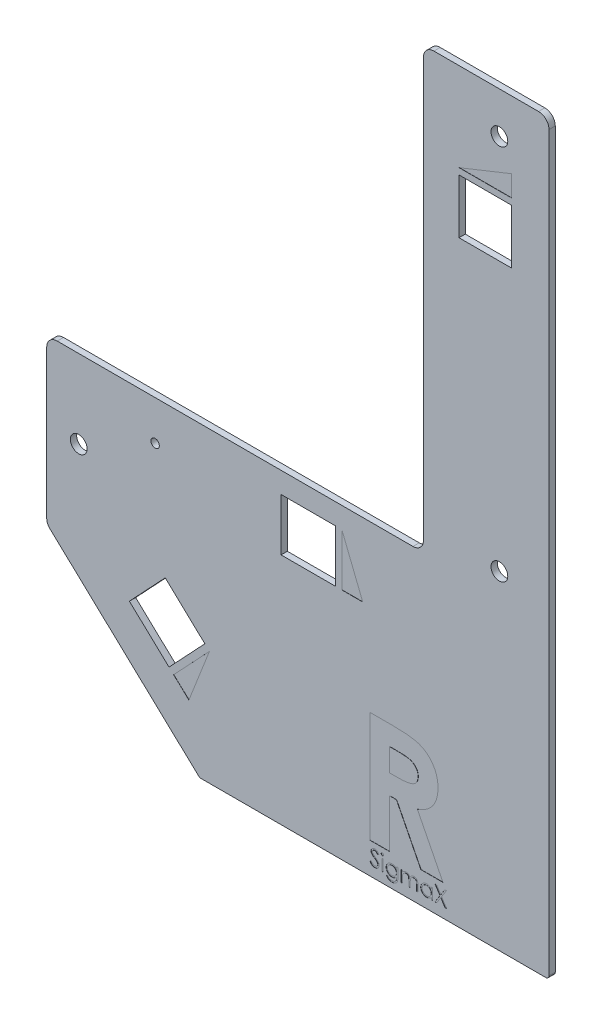
from build123d import *

# Parameters (mm, degrees)
SALIENTE_EXTRUIR1_DEPTH = 3
CROQUIS2_R              = 4
CROQUIS2_R_2            = 2
CROQUIS2_W              = 25
CROQUIS2_H              = 26
CROQUIS2_W_2            = 26
CROQUIS2_H_2            = 25
CORTAR_EXTRUIR1_DEPTH   = 3
CORTAR_EXTRUIR2_DEPTH   = 0.1
REDONDEO1_R             = 5
CROQUIS4_W              = 0.664850428
CROQUIS4_H              = 5.413782051
CORTAR_EXTRUIR3_DEPTH   = 0.1
CORTAR_EXTRUIR9_REACH   = 807.611
CROQUIS10_R             = 4


with BuildPart() as part:
    # Croquis1 → Saliente-Extruir1 (new body)
    with BuildSketch(Plane.XY):
        Polygon((676.577899016, -3.312104139), (676.577899016, -437.312104139), (591.996797016, -437.312104139), (436.577899016, -291.312104139), (436.577899016, -213.312104139), (616.577899016, -213.312104139), (616.577899016, -3.312104139), align=None)
    extrude(amount=SALIENTE_EXTRUIR1_DEPTH)

    # Croquis2 → Cortar-Extruir1 (cut)
    with BuildSketch(Plane.XY.offset(3)):
        with Locations((652.877899016, -23)):
            Circle(CROQUIS2_R)
        with Locations((652.877899016, -203)):
            Circle(CROQUIS2_R)
        with Locations((652.877899016, -383.180000139)):
            Circle(CROQUIS2_R)
        with Locations((488.377899016, -232.212104139)):
            Circle(CROQUIS2_R_2)
        with Locations((451.877899016, -250.812104139)):
            Circle(CROQUIS2_R)
        with Locations((646.077899016, -61.566115562)):
            Rectangle(CROQUIS2_W, CROQUIS2_H)
        with Locations((561.577899016, -235.812104139)):
            Rectangle(CROQUIS2_W_2, CROQUIS2_H_2)
        Polygon((476.073516686, -303.717618116), (495.023540448, -321.519207915), (512.140453717, -303.298031221), (493.190429955, -285.496441421), align=None)
    extrude(amount=-CORTAR_EXTRUIR1_DEPTH, mode=Mode.SUBTRACT)

    # Croquis3 → Cortar-Extruir2 (cut)
    # profile 1 of 4: a face of its own
    with BuildSketch(Plane.XY.offset(3)):
        Polygon((577.577899016, -248.312104139), (577.577899016, -223.312104139), (587.577899016, -248.312104139), align=None)
    # profile 2 of 4: a face of its own
    with BuildSketch(Plane.XY.offset(3)):
        Polygon((497.210081652, -323.573237508), (514.326994921, -305.352060813), (504.49855233, -330.420002815), align=None)
    # profile 3 of 4: a face of its own
    with BuildSketch(Plane.XY.offset(3)):
        Polygon((633.577899016, -45.566115562), (658.577899016, -35.566115562), (658.577899016, -45.566115562), align=None)
    # profile 4 of 4: a face of its own
    with BuildSketch(Plane.XY.offset(3)):
        with BuildLine():
            Line((590.974945428, -292.24933964), (602.041652159, -292.24933964))
            add(Edge.make_bspline(
                [(602.041652159, -292.24933964), (602.773158105, -292.251936067), (604.180050094, -292.256929726), (606.208711499, -292.335716439), (608.072315986, -292.445354618), (609.77362279, -292.612665388), (611.311904063, -292.834499245), (612.688701524, -293.096004654), (613.90397493, -293.394046133), (614.967973434, -293.76542933), (615.928179469, -294.184343946), (616.823224989, -294.665684521), (617.672856027, -295.204091176), (618.471393719, -295.813730847), (619.225777544, -296.483636267), (619.937430692, -297.214481761), (620.596296846, -298.012464599), (621.198296278, -298.87254254), (621.746970303, -299.777324812), (622.231883065, -300.728053685), (622.626214928, -301.72539033), (622.974649401, -302.754921074), (623.225615464, -303.831363263), (623.400158689, -304.944237549), (623.527952411, -306.097461368), (623.535299939, -306.880910429), (623.539047992, -307.280556254)],
                knots=[0, 0, 0, 0, 1.749336639, 3.364467119, 4.854658419, 6.213483162, 7.451590619, 8.570285859, 9.5643256, 10.440900261, 11.26203566, 12.067320669, 12.869050712, 13.665104639, 14.467235401, 15.27997916, 16.102287765, 16.939272006, 17.78853747, 18.631303466, 19.488103222, 20.351255419, 21.228522269, 22.127379805, 23.044756219, 24, 24, 24, 24], degree=3))
            add(Edge.make_bspline(
                [(623.539047992, -307.280556254), (623.529311897, -307.697694687), (623.51022119, -308.515627128), (623.407388254, -309.717103173), (623.219441949, -310.866591414), (622.934769929, -311.960726289), (622.607576417, -313.013125584), (622.172492976, -314.004371873), (621.68145831, -314.948881397), (621.098270785, -315.833293711), (620.458250966, -316.67725338), (619.71392138, -317.448425178), (618.913503151, -318.188256668), (618.012001854, -318.850407317), (617.049156505, -319.479649358), (616.00583638, -320.049910221), (614.888850543, -320.57552495), (614.103554183, -320.868644031), (613.701975343, -321.018537023)],
                knots=[0, 0, 0, 0, 1.099860209, 2.156625411, 3.176576793, 4.16617041, 5.135385252, 6.078461593, 7.016046972, 7.938469504, 8.868247731, 9.803980173, 10.76021508, 11.73834243, 12.748633912, 13.790971185, 14.870363756, 16, 16, 16, 16], degree=3))
            Line((613.701975343, -321.018537023), (625.913513804, -345.166006307))
            Line((625.913513804, -345.166006307), (615.355621176, -345.166006307))
            Line((615.355621176, -345.166006307), (603.695297992, -322.099766991))
            Line((603.695297992, -322.099766991), (600.472808676, -322.099766991))
            Line((600.472808676, -322.099766991), (600.472808676, -345.166006307))
            Line((600.472808676, -345.166006307), (590.974945428, -345.166006307))
            Line((590.974945428, -345.166006307), (590.974945428, -292.24933964))
        make_face()
        with BuildLine():
            Line((600.472808676, -312.601903743), (604.172311213, -312.601903743))
            add(Edge.make_bspline(
                [(604.172311213, -312.601903743), (604.624606151, -312.596809693), (605.49065377, -312.587055683), (606.736143993, -312.54181254), (607.86734615, -312.432798921), (608.889118004, -312.295064288), (609.806601017, -312.136029763), (610.611611566, -311.908123634), (611.316553634, -311.663916447), (611.913073631, -311.360430261), (612.422726609, -311.015300645), (612.862779336, -310.623224821), (613.226766038, -310.169446979), (613.526345658, -309.666298843), (613.759386033, -309.109330192), (613.929487653, -308.504655279), (614.024549304, -307.845386079), (614.035486471, -307.390400563), (614.041184744, -307.153352728)],
                knots=[0, 0, 0, 0, 1.688639943, 3.233382647, 4.650958383, 5.928841754, 7.082724185, 8.122798841, 9.049171256, 9.863274652, 10.613301712, 11.341792392, 12.054588806, 12.776240173, 13.521029143, 14.301969904, 15.115324896, 16, 16, 16, 16], degree=3))
            add(Edge.make_bspline(
                [(614.041184744, -307.153352728), (614.030411637, -306.872907833), (614.009249864, -306.322025807), (613.799259333, -305.528948853), (613.464999768, -304.794901871), (613.006821456, -304.123201467), (612.429805438, -303.534342523), (611.767634033, -303.015258675), (611.006015983, -302.604806009), (610.300814981, -302.3340758), (609.659246905, -302.172095123), (609.080251956, -302.051388555), (608.409772321, -301.965840346), (607.647301821, -301.875101242), (606.794784022, -301.816261527), (605.847572191, -301.773320262), (604.808386714, -301.755750882), (604.083975738, -301.75013426), (603.705898286, -301.747202888)],
                knots=[0, 0, 0, 0, 1.020303359, 2.004196876, 2.966617323, 3.9489082, 4.950758222, 5.960522915, 7.003732012, 8.091992268, 8.70421221, 9.413913587, 10.24622431, 11.166358409, 12.212345909, 13.359657661, 14.621978493, 16, 16, 16, 16], degree=3))
            Line((603.705898286, -301.747202888), (600.472808676, -301.747202888))
            Line((600.472808676, -301.747202888), (600.472808676, -312.601903743))
        make_face(mode=Mode.SUBTRACT)
    extrude(amount=-CORTAR_EXTRUIR2_DEPTH, mode=Mode.SUBTRACT)

    # Redondeo1
    redondeo1_edges = [part.edges().sort_by_distance(p)[0] for p in [
        (591.996797016, -437.312104139, 1.5),
        (676.577899016, -437.312104139, 1.5),
        (676.577899016, -3.312104139, 1.5),
        (616.577899016, -3.312104139, 1.5),
        (616.577899016, -213.312104139, 1.5),
        (436.577899016, -213.312104139, 1.5),
        (436.577899016, -291.312104139, 1.5),
    ]]
    fillet(redondeo1_edges, radius=REDONDEO1_R)

    # Croquis4 → Cortar-Extruir3 (cut)
    # profile 1 of 7: a face of its own
    with BuildSketch(Plane.XY.offset(3)):
        with BuildLine():
            Line((591.064902693, -353.736874696), (591.691168051, -353.36141229))
            add(Edge.make_bspline(
                [(591.691168051, -353.36141229), (591.749414986, -353.458915238), (591.861013867, -353.645727124), (592.047177577, -353.898156643), (592.240075573, -354.112706541), (592.441136329, -354.288128694), (592.649132585, -354.426238838), (592.865422166, -354.524033561), (593.089276199, -354.585027376), (593.241620787, -354.592435892), (593.317677132, -354.596134512)],
                knots=[0, 0, 0, 0, 1.272034388, 2.437168799, 3.508375237, 4.49857839, 5.41946034, 6.295179144, 7.148887113, 8, 8, 8, 8], degree=3))
            add(Edge.make_bspline(
                [(593.317677132, -354.596134512), (593.382630987, -354.594325455), (593.511402156, -354.590738996), (593.700975571, -354.556277965), (593.885087052, -354.503335625), (594.059942002, -354.427514654), (594.223127719, -354.335781526), (594.366228558, -354.224982117), (594.489939497, -354.100932314), (594.591135457, -353.962539029), (594.668774865, -353.813701064), (594.728448076, -353.660928634), (594.761563482, -353.501821831), (594.766551944, -353.394696351), (594.76906936, -353.340635714)],
                knots=[0, 0, 0, 0, 1.095163259, 2.171163733, 3.241058638, 4.321873601, 5.38011039, 6.391990106, 7.366004449, 8.327778327, 9.272591725, 10.192022065, 11.087607919, 12, 12, 12, 12], degree=3))
            add(Edge.make_bspline(
                [(594.76906936, -353.340635714), (594.765948735, -353.278954249), (594.759604962, -353.153564843), (594.705986663, -352.968568911), (594.62163909, -352.785492972), (594.543824828, -352.672248626), (594.503425997, -352.613455559)],
                knots=[0, 0, 0, 0, 0.938893495, 1.908633276, 2.914225137, 4, 4, 4, 4], degree=3))
            add(Edge.make_bspline(
                [(594.503425997, -352.613455559), (594.47025653, -352.571023116), (594.400621384, -352.481941509), (594.280907982, -352.349342427), (594.14043304, -352.212566774), (593.984003849, -352.06639177), (593.805922144, -351.917615933), (593.611765572, -351.759144745), (593.396577071, -351.59700474), (593.245659803, -351.488266143), (593.167788978, -351.432158818)],
                knots=[0, 0, 0, 0, 0.722233717, 1.516239348, 2.393582979, 3.351407094, 4.387010283, 5.505090956, 6.712668013, 8, 8, 8, 8], degree=3))
            add(Edge.make_bspline(
                [(593.167788978, -351.432158818), (593.089844852, -351.376641641), (592.94082162, -351.270497025), (592.732417621, -351.112965624), (592.546056841, -350.968939434), (592.382567589, -350.837062608), (592.242021776, -350.717317261), (592.123311889, -350.61085329), (592.029461944, -350.51479142), (591.977274298, -350.452473913), (591.953843331, -350.424494889)],
                knots=[0, 0, 0, 0, 1.452282411, 2.77665338, 3.964542531, 5.026858415, 5.96415736, 6.766646006, 7.446254459, 8, 8, 8, 8], degree=3))
            add(Edge.make_bspline(
                [(591.953843331, -350.424494889), (591.921093111, -350.380889361), (591.856685406, -350.295133238), (591.771667361, -350.161095622), (591.699406133, -350.023886377), (591.642759197, -349.883136797), (591.595057534, -349.740822864), (591.562973247, -349.595087728), (591.542883124, -349.446585318), (591.540825752, -349.346650075), (591.539795855, -349.296623628)],
                knots=[0, 0, 0, 0, 1.068054152, 2.10047183, 3.106115577, 4.101338837, 5.06977816, 6.043150881, 7.020423561, 8, 8, 8, 8], degree=3))
            add(Edge.make_bspline(
                [(591.539795855, -349.296623628), (591.542558548, -349.218243939), (591.548024882, -349.06315987), (591.594253977, -348.836611279), (591.667221602, -348.620316696), (591.769445781, -348.41641749), (591.901223845, -348.23022283), (592.053721157, -348.059590949), (592.23535547, -347.91614745), (592.434645189, -347.79081526), (592.652781176, -347.692716385), (592.881361922, -347.618715644), (593.120750724, -347.576786048), (593.282894026, -347.570768863), (593.365166448, -347.567715709)],
                knots=[0, 0, 0, 0, 1.005424448, 1.989358655, 2.955360095, 3.929531133, 4.905563448, 5.876582895, 6.856512386, 7.866279853, 8.892233794, 9.918561126, 10.94386622, 12, 12, 12, 12], degree=3))
            add(Edge.make_bspline(
                [(593.365166448, -347.567715709), (593.452466461, -347.570726776), (593.626078322, -347.576714829), (593.881452495, -347.628779603), (594.127326011, -347.714929359), (594.325114255, -347.812695351), (594.479911933, -347.910340181), (594.597964218, -347.999282143), (594.717592822, -348.101676122), (594.839762705, -348.21779486), (594.962403767, -348.348703816), (595.087336741, -348.493506441), (595.214853777, -348.651317818), (595.296887014, -348.763976344), (595.338941154, -348.821730466)],
                knots=[0, 0, 0, 0, 1.286793592, 2.559021753, 3.825965368, 5.121522368, 5.803751409, 6.523245864, 7.299691795, 8.125521123, 9.008227632, 9.944561021, 10.946284179, 12, 12, 12, 12], degree=3))
            Line((595.338941154, -348.821730466), (594.737904496, -349.277331093))
            add(Edge.make_bspline(
                [(594.737904496, -349.277331093), (594.701612272, -349.230576699), (594.631721935, -349.140538666), (594.525614521, -349.014446048), (594.425604883, -348.8992645), (594.327073203, -348.799219979), (594.23522335, -348.708833796), (594.14607561, -348.631448978), (594.0609129, -348.566307301), (593.953562106, -348.496788432), (593.818692936, -348.427877166), (593.649392334, -348.369564951), (593.472468052, -348.334523403), (593.351966998, -348.329890258), (593.290964392, -348.327544769)],
                knots=[0, 0, 0, 0, 1.181633172, 2.275549214, 3.290209073, 4.226197932, 5.078386478, 5.862611352, 6.581680152, 7.217281963, 8.414376989, 9.595101626, 10.782541182, 12, 12, 12, 12], degree=3))
            add(Edge.make_bspline(
                [(593.290964392, -348.327544769), (593.214433086, -348.330109533), (593.066849672, -348.335055441), (592.857320339, -348.389072743), (592.668738198, -348.474124347), (592.506701935, -348.593324384), (592.371792, -348.734550486), (592.274202113, -348.897065729), (592.215464264, -349.076521814), (592.208296639, -349.201704987), (592.204646283, -349.265458764)],
                knots=[0, 0, 0, 0, 1.14458467, 2.207223713, 3.21896685, 4.227309161, 5.202851033, 6.127160689, 7.046193047, 8, 8, 8, 8], degree=3))
            add(Edge.make_bspline(
                [(592.204646283, -349.265458764), (592.205478401, -349.305149394), (592.207143998, -349.384595555), (592.230373986, -349.501967731), (592.260217566, -349.6190434), (592.307509469, -349.7352962), (592.372798695, -349.85275926), (592.458534651, -349.973455271), (592.566512828, -350.098448055), (592.649225838, -350.179743663), (592.692895815, -350.222665295)],
                knots=[0, 0, 0, 0, 0.858281714, 1.717966888, 2.583508476, 3.4729293, 4.427298488, 5.488583878, 6.674047936, 8, 8, 8, 8], degree=3))
            add(Edge.make_bspline(
                [(592.692895815, -350.222665295), (592.709112387, -350.237136999), (592.747639249, -350.271518457), (592.818073292, -350.327805451), (592.911085548, -350.397237986), (593.024247207, -350.483147806), (593.15964479, -350.582803567), (593.317293183, -350.694931046), (593.495435095, -350.823170268), (593.621846483, -350.912827062), (593.688687415, -350.960233738)],
                knots=[0, 0, 0, 0, 0.420754252, 0.999615792, 1.744751191, 2.668019286, 3.750313428, 4.999500688, 6.413464383, 8, 8, 8, 8], degree=3))
            add(Edge.make_bspline(
                [(593.688687415, -350.960233738), (593.769090932, -351.018741282), (593.924781198, -351.132033033), (594.146306408, -351.302246222), (594.347164969, -351.468717332), (594.528062083, -351.630383267), (594.690784873, -351.786017731), (594.833528048, -351.937493129), (594.957746072, -352.083724258), (595.091475417, -352.271202876), (595.228122802, -352.501456172), (595.345473993, -352.783561776), (595.419469161, -353.066763988), (595.429145536, -353.257109125), (595.433919787, -353.351024002)],
                knots=[0, 0, 0, 0, 1.163667725, 2.253281268, 3.268753668, 4.215851969, 5.092017293, 5.902905408, 6.650798638, 7.335211899, 8.59617414, 9.77448103, 10.901945474, 12, 12, 12, 12], degree=3))
            add(Edge.make_bspline(
                [(595.433919787, -353.351024002), (595.432528845, -353.417441541), (595.429773971, -353.548986837), (595.398106704, -353.742143416), (595.351710079, -353.929745424), (595.281781267, -354.109473945), (595.196430582, -354.284617026), (595.088128691, -354.450580415), (594.962594091, -354.611037292), (594.818589289, -354.761709015), (594.661012129, -354.90002513), (594.494464975, -355.023064977), (594.318675231, -355.125656262), (594.134596527, -355.209372211), (593.942186581, -355.274848156), (593.741510106, -355.322288729), (593.532236307, -355.351404984), (593.389995288, -355.354427079), (593.317677132, -355.355963572)],
                knots=[0, 0, 0, 0, 0.983748083, 1.948392443, 2.894712957, 3.844097841, 4.80183111, 5.778335162, 6.776009319, 7.81870978, 8.863265674, 9.881300176, 10.883814829, 11.87499822, 12.874611388, 13.892143829, 14.928324115, 16, 16, 16, 16], degree=3))
            add(Edge.make_bspline(
                [(593.317677132, -355.355963572), (593.261722323, -355.354881571), (593.150517397, -355.352731196), (592.986032327, -355.333720819), (592.824870197, -355.306824116), (592.6690533, -355.264122335), (592.516574112, -355.212312733), (592.368095799, -355.148519929), (592.223546402, -355.072071853), (592.082115851, -354.984664051), (591.944163848, -354.882941825), (591.810984308, -354.764464591), (591.678207532, -354.632499938), (591.549752543, -354.483464246), (591.423021054, -354.319765304), (591.300511754, -354.139871532), (591.179688785, -353.9447628), (591.103879378, -353.807465035), (591.064902693, -353.736874696)],
                knots=[0, 0, 0, 0, 0.915332311, 1.819136955, 2.706846663, 3.586547465, 4.459518054, 5.340707479, 6.227863349, 7.133153174, 8.059268498, 9.028702269, 10.047606654, 11.120612155, 12.245963614, 13.433783089, 14.680604001, 16, 16, 16, 16], degree=3))
        make_face()
    # profile 2 of 7: a face of its own
    with BuildSketch(Plane.XY.offset(3)):
        with BuildLine():
            add(Edge.make_bspline(
                [(596.998099141, -347.472737076), (597.039355759, -347.474650865), (597.120144142, -347.478398432), (597.236969892, -347.510490226), (597.343347234, -347.564887893), (597.437703435, -347.637869884), (597.518669929, -347.72369954), (597.575355766, -347.823735256), (597.611788671, -347.931809375), (597.616188279, -348.007194647), (597.618428334, -348.045576953)],
                knots=[0, 0, 0, 0, 1.055194115, 2.066272739, 3.074728998, 4.095836921, 5.109056067, 6.073838105, 7.019297344, 8, 8, 8, 8], degree=3))
            add(Edge.make_bspline(
                [(597.618428334, -348.045576953), (597.616137762, -348.082962903), (597.611609573, -348.1568705), (597.575383907, -348.263071016), (597.518186836, -348.361716749), (597.437755354, -348.447379752), (597.343333476, -348.520321398), (597.236973546, -348.574729762), (597.12014318, -348.606818719), (597.039355434, -348.610566677), (596.998099141, -348.612480666)],
                knots=[0, 0, 0, 0, 0.96129708, 1.900370562, 2.859976407, 3.87933698, 4.906634145, 5.921202961, 6.938410037, 8, 8, 8, 8], degree=3))
            add(Edge.make_bspline(
                [(596.998099141, -348.612480666), (596.957314625, -348.610639758), (596.877932893, -348.607056672), (596.762856411, -348.574100134), (596.657386108, -348.520302779), (596.562845884, -348.447857354), (596.484041975, -348.361190655), (596.426683853, -348.263131216), (596.390541851, -348.156855173), (596.386002387, -348.082957754), (596.383706112, -348.045576953)],
                knots=[0, 0, 0, 0, 1.054934014, 2.053291228, 3.073705704, 4.106921865, 5.123545215, 6.088680038, 7.033164197, 8, 8, 8, 8], degree=3))
            add(Edge.make_bspline(
                [(596.383706112, -348.045576953), (596.385952078, -348.007199988), (596.390363299, -347.931825208), (596.426710945, -347.823674055), (596.483564204, -347.724229876), (596.562898064, -347.637392569), (596.657372221, -347.564906398), (596.762859999, -347.511119821), (596.877931946, -347.478160486), (596.957314303, -347.474577786), (596.998099141, -347.472737076)],
                knots=[0, 0, 0, 0, 0.98631895, 1.937192651, 2.907499808, 3.917963147, 4.944918757, 5.95915025, 6.951458133, 8, 8, 8, 8], degree=3))
        make_face()
    # profile 3 of 7: a face of its own
    with BuildSketch(Plane.XY.offset(3)):
        with Locations((597.001067223, -352.459115282)):
            Rectangle(CROQUIS4_W, CROQUIS4_H)
    # profile 4 of 7: a face of its own
    with BuildSketch(Plane.XY.offset(3)):
        with BuildLine():
            Line((603.697060813, -349.752224256), (604.36191124, -349.752224256))
            Line((604.36191124, -349.752224256), (604.36191124, -354.048523334))
            add(Edge.make_bspline(
                [(604.36191124, -354.048523334), (604.361324833, -354.14004291), (604.360192927, -354.316697735), (604.352041704, -354.572133427), (604.334852938, -354.808069975), (604.315361229, -355.025583422), (604.287322346, -355.223665555), (604.253082369, -355.402907438), (604.214483514, -355.563481079), (604.180574054, -355.662381992), (604.164533769, -355.709165361)],
                knots=[0, 0, 0, 0, 1.307562039, 2.523909702, 3.650326591, 4.686913197, 5.643429486, 6.506965704, 7.293745905, 8, 8, 8, 8], degree=3))
            add(Edge.make_bspline(
                [(604.164533769, -355.709165361), (604.140849881, -355.769977029), (604.094190236, -355.889782134), (604.006802312, -356.059611446), (603.90894055, -356.219517971), (603.797166261, -356.368610577), (603.671984892, -356.506140808), (603.536345734, -356.635096606), (603.387607162, -356.752749761), (603.225854221, -356.857070307), (603.054815631, -356.951022905), (602.874589715, -357.032401472), (602.686192754, -357.103281958), (602.487854966, -357.156373875), (602.28268597, -357.202379034), (602.068273074, -357.232318619), (601.845868988, -357.252695892), (601.694642933, -357.254580218), (601.617919186, -357.255536222)],
                knots=[0, 0, 0, 0, 0.981931301, 1.934503488, 2.87077864, 3.801706999, 4.735015492, 5.667491629, 6.616593066, 7.585388521, 8.561939025, 9.551802639, 10.560317337, 11.588439944, 12.640189604, 13.723962949, 14.845264515, 16, 16, 16, 16], degree=3))
            add(Edge.make_bspline(
                [(601.617919186, -357.255536222), (601.505979831, -357.253723327), (601.287332196, -357.250182256), (600.968551628, -357.208926485), (600.665794805, -357.150603062), (600.383062204, -357.062326574), (600.122140499, -356.954298279), (599.88481163, -356.830272295), (599.673206119, -356.688054925), (599.482444344, -356.526128653), (599.310271312, -356.33358886), (599.148288548, -356.10668464), (598.992372888, -355.841959725), (598.900999271, -355.647665148), (598.853150556, -355.545920837)],
                knots=[0, 0, 0, 0, 1.157897085, 2.2616841, 3.32207898, 4.345638746, 5.321241055, 6.241986252, 7.112515963, 7.955008012, 8.825025602, 9.77857164, 10.836726669, 12, 12, 12, 12], degree=3))
            Line((598.853150556, -355.545920837), (599.518000984, -355.545920837))
            add(Edge.make_bspline(
                [(599.518000984, -355.545920837), (599.57147266, -355.630811607), (599.676003203, -355.79676261), (599.871474154, -356.011632123), (600.085694212, -356.195260079), (600.325892874, -356.343237884), (600.59306958, -356.454806942), (600.887385066, -356.53434132), (601.211234265, -356.581958418), (601.436697819, -356.587697324), (601.554105417, -356.590685794)],
                knots=[0, 0, 0, 0, 0.997731894, 1.950442991, 2.880492273, 3.800895997, 4.748200782, 5.754801363, 6.83083817, 8, 8, 8, 8], degree=3))
            add(Edge.make_bspline(
                [(601.554105417, -356.590685794), (601.670028669, -356.587658646), (601.893517093, -356.581822607), (602.214893068, -356.534320069), (602.508252354, -356.454789634), (602.771904778, -356.343435216), (603.002739488, -356.207015189), (603.201731536, -356.054615032), (603.362904434, -355.882781908), (603.471305214, -355.724493752), (603.538688488, -355.583472678), (603.581598056, -355.46207635), (603.616467958, -355.324804425), (603.64563528, -355.172117117), (603.669703714, -355.003796276), (603.684949815, -354.819457039), (603.695968782, -354.619518352), (603.696688385, -354.480891209), (603.697060813, -354.409145329)],
                knots=[0, 0, 0, 0, 1.570740765, 3.028230971, 4.391408896, 5.680370741, 6.894727393, 8.017376726, 9.065722033, 10.075533815, 10.603371122, 11.180248986, 11.817768598, 12.521299649, 13.286540596, 14.121245857, 15.027658897, 16, 16, 16, 16], degree=3))
            Line((603.697060813, -354.409145329), (603.697060813, -354.128661555))
            add(Edge.make_bspline(
                [(603.697060813, -354.128661555), (603.629579114, -354.208971703), (603.495802699, -354.368179368), (603.26477419, -354.576801499), (603.012431719, -354.756477142), (602.739204888, -354.903836585), (602.451786442, -355.0216956), (602.153289387, -355.104124867), (601.846389537, -355.157379989), (601.638422487, -355.163110475), (601.533328841, -355.166006307)],
                knots=[0, 0, 0, 0, 1.012485704, 2.007162095, 2.997754123, 3.998611389, 4.999708251, 5.992315798, 6.98544096, 8, 8, 8, 8], degree=3))
            add(Edge.make_bspline(
                [(601.533328841, -355.166006307), (601.471445405, -355.164916168), (601.348410858, -355.16274879), (601.165626643, -355.143786044), (600.985539715, -355.11627204), (600.808570076, -355.075882994), (600.634462361, -355.024042173), (600.463504291, -354.959236742), (600.29431166, -354.885968075), (600.129959906, -354.799665641), (599.97208593, -354.703648758), (599.821880521, -354.599638106), (599.680130447, -354.488178063), (599.548184877, -354.36816954), (599.426216889, -354.239786229), (599.312586035, -354.104396709), (599.209171317, -353.96011044), (599.113850643, -353.809558379), (599.031178828, -353.651737757), (598.958610241, -353.490070789), (598.895513667, -353.324903152), (598.845210234, -353.155681869), (598.806790377, -352.982513625), (598.77819373, -352.805682108), (598.761973858, -352.624642788), (598.759444602, -352.502677599), (598.758171924, -352.441306788)],
                knots=[0, 0, 0, 0, 1.028754217, 2.045334182, 3.052854819, 4.056607503, 5.061168794, 6.071104265, 7.095078842, 8.125279047, 9.155117945, 10.165957491, 11.161587969, 12.151493252, 13.128948131, 14.104219989, 15.088194871, 16.07871515, 17.064853787, 18.047899887, 19.02414258, 20.002704429, 20.980574569, 21.971845993, 22.979467364, 24, 24, 24, 24], degree=3))
            add(Edge.make_bspline(
                [(598.758171924, -352.441306788), (598.759270826, -352.379916901), (598.761464373, -352.2573749), (598.780410613, -352.075596868), (598.807436614, -351.896252896), (598.850209725, -351.721191563), (598.901692398, -351.548419172), (598.96545396, -351.379211873), (599.042117, -351.213518128), (599.12892097, -351.051215237), (599.226465633, -350.894481118), (599.333426051, -350.745623051), (599.449931351, -350.605736421), (599.574374239, -350.473409994), (599.708274185, -350.3499205), (599.851561919, -350.235567658), (600.002825016, -350.128434636), (600.162532278, -350.030832306), (600.328219417, -349.944509884), (600.495676998, -349.86574322), (600.667123262, -349.803229334), (600.839361804, -349.748147108), (601.015425957, -349.709125944), (601.19315694, -349.679022199), (601.373163222, -349.660681873), (601.493713516, -349.658392518), (601.554105417, -349.657245623)],
                knots=[0, 0, 0, 0, 1.008818848, 2.013730394, 3.001654427, 3.987803273, 4.973046549, 5.963777569, 6.957074694, 7.972068341, 8.987420212, 9.989399531, 10.982630087, 11.977756091, 12.973280677, 13.973972381, 14.989194003, 16.018387222, 17.047741039, 18.059210846, 19.057554164, 20.045176975, 21.029480261, 22.018708529, 23.007435371, 24, 24, 24, 24], degree=3))
            add(Edge.make_bspline(
                [(601.554105417, -349.657245623), (601.653696571, -349.660117248), (601.8503585, -349.665787826), (602.139772455, -349.710282583), (602.419050196, -349.781220578), (602.689767663, -349.882853663), (602.954130124, -350.021601244), (603.211266295, -350.204360484), (603.461920129, -350.432770703), (603.616601537, -350.607930933), (603.697060813, -350.699042498)],
                knots=[0, 0, 0, 0, 0.96728863, 1.910097829, 2.838038873, 3.762875196, 4.71315279, 5.730631239, 6.819562287, 8, 8, 8, 8], degree=3))
            Line((603.697060813, -350.699042498), (603.697060813, -349.752224256))
        make_face()
        with BuildLine():
            add(Edge.make_bspline(
                [(601.607530898, -350.322096051), (601.510310908, -350.325400306), (601.317835943, -350.331942031), (601.035708951, -350.387789674), (600.763342776, -350.475305162), (600.505944619, -350.600490365), (600.264841237, -350.753089835), (600.050899533, -350.93796011), (599.863775794, -351.14908956), (599.705485242, -351.38456925), (599.579477183, -351.6386164), (599.490273611, -351.906397454), (599.432594395, -352.183585522), (599.426228199, -352.372757532), (599.423022351, -352.468019528)],
                knots=[0, 0, 0, 0, 1.026226791, 2.031711442, 3.026614839, 4.04107745, 5.047145931, 6.032893242, 7.017642609, 8.019221815, 9.021877557, 10.003543541, 10.994637589, 12, 12, 12, 12], degree=3))
            add(Edge.make_bspline(
                [(599.423022351, -352.468019528), (599.424558536, -352.539844955), (599.427579764, -352.681104566), (599.456628003, -352.888406443), (599.503577713, -353.085849774), (599.570119799, -353.273446499), (599.65256967, -353.452272649), (599.756270189, -353.621096362), (599.878298079, -353.78006799), (600.017698227, -353.928011733), (600.171318236, -354.062760783), (600.337940541, -354.181162969), (600.517339153, -354.278001995), (600.705101901, -354.361696768), (600.905784668, -354.422824128), (601.1164969, -354.469472877), (601.338729324, -354.496161414), (601.490222839, -354.499469336), (601.567461788, -354.50115588)],
                knots=[0, 0, 0, 0, 1.039728707, 2.044842319, 3.024901384, 3.974314358, 4.923051295, 5.871625912, 6.837440708, 7.820715446, 8.810779094, 9.792721783, 10.773906224, 11.758876063, 12.764959493, 13.806266761, 14.881525401, 16, 16, 16, 16], degree=3))
            add(Edge.make_bspline(
                [(601.567461788, -354.50115588), (601.645701742, -354.499531107), (601.798699145, -354.496353882), (602.022157627, -354.469041477), (602.233893594, -354.424968293), (602.433712901, -354.362393223), (602.622370007, -354.282548851), (602.797745608, -354.181506344), (602.963600089, -354.066434963), (603.114637823, -353.932212866), (603.251213973, -353.784289627), (603.370235763, -353.623327932), (603.47165468, -353.451749834), (603.555639082, -353.269574672), (603.619755464, -353.075386691), (603.662763813, -352.869671338), (603.692834757, -352.653414174), (603.695630714, -352.50522927), (603.697060813, -352.429434459)],
                knots=[0, 0, 0, 0, 1.121943988, 2.193949579, 3.223793937, 4.220241907, 5.192961521, 6.155822191, 7.11847367, 8.083710714, 9.04790392, 10.001595906, 10.949595423, 11.902125208, 12.873731292, 13.87582262, 14.913508608, 16, 16, 16, 16], degree=3))
            add(Edge.make_bspline(
                [(603.697060813, -352.429434459), (603.694225393, -352.330760001), (603.68868598, -352.137984786), (603.63641033, -351.857088793), (603.552124218, -351.592995101), (603.433915259, -351.346538952), (603.285786674, -351.120331738), (603.107371044, -350.918562934), (602.90174528, -350.740972788), (602.669500168, -350.593021611), (602.419633075, -350.473503108), (602.158179877, -350.383837357), (601.885528733, -350.333049391), (601.700730166, -350.325768177), (601.607530898, -350.322096051)],
                knots=[0, 0, 0, 0, 1.070913519, 2.092188694, 3.091357305, 4.074328408, 5.051968682, 6.018948707, 6.99050112, 7.9935919, 9.000589572, 9.992915277, 10.987769056, 12, 12, 12, 12], degree=3))
        make_face(mode=Mode.SUBTRACT)
    # profile 5 of 7: a face of its own
    with BuildSketch(Plane.XY.offset(3)):
        with BuildLine():
            Line((605.88156936, -349.752224256), (606.546419787, -349.752224256))
            Line((606.546419787, -349.752224256), (606.546419787, -350.693106334))
            add(Edge.make_bspline(
                [(606.546419787, -350.693106334), (606.606287481, -350.610794243), (606.720999722, -350.453076387), (606.909098687, -350.245240285), (607.097008125, -350.068862358), (607.232333783, -349.97627328), (607.2973446, -349.931793233)],
                knots=[0, 0, 0, 0, 1.134379233, 2.173579362, 3.122582517, 4, 4, 4, 4], degree=3))
            add(Edge.make_bspline(
                [(607.2973446, -349.931793233), (607.385958135, -349.889448543), (607.561637023, -349.805498975), (607.839807715, -349.720337942), (608.124445766, -349.668003144), (608.316656485, -349.660845903), (608.413343532, -349.657245623)],
                knots=[0, 0, 0, 0, 1.014936303, 2.012140481, 3.000054389, 4, 4, 4, 4], degree=3))
            add(Edge.make_bspline(
                [(608.413343532, -349.657245623), (608.478733708, -349.659458155), (608.60813735, -349.663836638), (608.799873674, -349.692327045), (608.985841069, -349.741573778), (609.164940765, -349.810169281), (609.333682869, -349.893241435), (609.488388338, -349.990713316), (609.627292912, -350.100138793), (609.750326387, -350.226459201), (609.860962491, -350.373221668), (609.962729383, -350.544384328), (610.056762749, -350.743790544), (610.108877852, -350.888499722), (610.136315286, -350.964685861)],
                knots=[0, 0, 0, 0, 1.009824226, 1.998387844, 2.986035974, 3.974953746, 4.955485308, 5.885931332, 6.793869504, 7.679848016, 8.601185859, 9.625726857, 10.749998409, 12, 12, 12, 12], degree=3))
            add(Edge.make_bspline(
                [(610.136315286, -350.964685861), (610.165337435, -350.912352507), (610.222448948, -350.809367815), (610.31834588, -350.663617827), (610.418819382, -350.527290118), (610.524725726, -350.400276519), (610.635691102, -350.283204257), (610.752237732, -350.175686265), (610.873702186, -350.077260812), (611.042595761, -349.962276791), (611.262332446, -349.840142624), (611.539378956, -349.734249084), (611.827563486, -349.668809946), (612.023180947, -349.661125869), (612.121962322, -349.657245623)],
                knots=[0, 0, 0, 0, 0.86119277, 1.694706429, 2.50939023, 3.298075842, 4.073795165, 4.829715201, 5.57930267, 6.321991688, 7.768977793, 9.186738141, 10.579381044, 12, 12, 12, 12], degree=3))
            add(Edge.make_bspline(
                [(612.121962322, -349.657245623), (612.212728085, -349.660668741), (612.390365496, -349.667368114), (612.648974041, -349.719974633), (612.890150863, -349.810308986), (613.113410674, -349.933570183), (613.314832279, -350.088466121), (613.489915133, -350.272761827), (613.637595736, -350.485153713), (613.734070523, -350.684950089), (613.799507832, -350.86134321), (613.839854112, -351.01163986), (613.875498133, -351.177060647), (613.905091769, -351.357803367), (613.926721037, -351.554506488), (613.942745718, -351.766848109), (613.953591674, -351.994993262), (613.95435806, -352.152400237), (613.95475312, -352.233541029)],
                knots=[0, 0, 0, 0, 1.209669288, 2.367440248, 3.500751976, 4.631527125, 5.755587489, 6.87532382, 8.007944318, 9.190864318, 9.82315674, 10.514484317, 11.263564316, 12.079023757, 12.955305781, 13.901327259, 14.918167583, 16, 16, 16, 16], degree=3))
            Line((613.95475312, -352.233541029), (613.95475312, -355.166006307))
            Line((613.95475312, -355.166006307), (613.289902693, -355.166006307))
            Line((613.289902693, -355.166006307), (613.289902693, -352.230572947))
            add(Edge.make_bspline(
                [(613.289902693, -352.230572947), (613.289737841, -352.161314399), (613.28942102, -352.028210002), (613.283719499, -351.837175647), (613.272976751, -351.663040958), (613.260415099, -351.506043371), (613.242965703, -351.365816769), (613.220431814, -351.242642816), (613.196560725, -351.135552582), (613.156902877, -351.016837115), (613.093513173, -350.885878503), (612.996956174, -350.744646934), (612.875311115, -350.62170924), (612.734848784, -350.514990469), (612.574937909, -350.428220596), (612.398694245, -350.366253042), (612.207212003, -350.327892949), (612.074660434, -350.324070216), (612.006207113, -350.322096051)],
                knots=[0, 0, 0, 0, 1.253487763, 2.409012846, 3.458416907, 4.410876679, 5.259312806, 6.014470957, 6.676830364, 7.243083969, 8.276244668, 9.299465089, 10.325150304, 11.392391894, 12.482080715, 13.603491619, 14.762376348, 16, 16, 16, 16], degree=3))
            add(Edge.make_bspline(
                [(612.006207113, -350.322096051), (611.922239043, -350.325093584), (611.756286215, -350.331017849), (611.514043269, -350.391499213), (611.281271284, -350.482685744), (611.064915919, -350.614834445), (610.865890429, -350.773178815), (610.694652989, -350.961455459), (610.55319153, -351.174455471), (610.457403947, -351.371615991), (610.396889926, -351.548716314), (610.356933788, -351.703439085), (610.325853943, -351.87929507), (610.296706322, -352.075102592), (610.277682298, -352.292209474), (610.260392577, -352.529611423), (610.252305084, -352.78802247), (610.251173813, -352.967148961), (610.250586454, -353.06015194)],
                knots=[0, 0, 0, 0, 1.090531906, 2.155305635, 3.229839962, 4.33261226, 5.44038871, 6.529323825, 7.629011124, 8.757537029, 9.370236727, 10.061839251, 10.834451254, 11.692844982, 12.636905849, 13.66920014, 14.789842145, 16, 16, 16, 16], degree=3))
            Line((610.250586454, -353.06015194), (610.250586454, -355.166006307))
            Line((610.250586454, -355.166006307), (609.585736026, -355.166006307))
            Line((609.585736026, -355.166006307), (609.585736026, -352.413110006))
            add(Edge.make_bspline(
                [(609.585736026, -352.413110006), (609.585567897, -352.335442482), (609.585244434, -352.186017971), (609.579579563, -351.971740024), (609.56881288, -351.776835072), (609.556365719, -351.60152964), (609.538458341, -351.446142327), (609.518117678, -351.309840089), (609.494096453, -351.192964633), (609.45432453, -351.064772135), (609.393545572, -350.923546181), (609.295780418, -350.772964353), (609.173844373, -350.641163547), (609.030819352, -350.528644196), (608.869940658, -350.435634727), (608.692175793, -350.368621586), (608.499125394, -350.329623506), (608.36603425, -350.324652522), (608.297588323, -350.322096051)],
                knots=[0, 0, 0, 0, 1.320475261, 2.540461679, 3.643808994, 4.639130445, 5.527981419, 6.302341397, 6.981980563, 7.553956391, 8.582137848, 9.585246428, 10.591171744, 11.620968678, 12.668337649, 13.738356861, 14.836885341, 16, 16, 16, 16], degree=3))
            add(Edge.make_bspline(
                [(608.297588323, -350.322096051), (608.217120676, -350.325335524), (608.056751512, -350.33179168), (607.821162343, -350.389903227), (607.593650979, -350.480928518), (607.377846866, -350.607208469), (607.179569919, -350.763628185), (607.005985753, -350.947598048), (606.860057408, -351.156828502), (606.7632584, -351.351910062), (606.700819963, -351.524573494), (606.659343171, -351.671366333), (606.623699296, -351.834350192), (606.597211284, -352.01402791), (606.571641071, -352.209229226), (606.55930025, -352.420926563), (606.547295443, -352.648938315), (606.546718832, -352.806360203), (606.546419787, -352.888003169)],
                knots=[0, 0, 0, 0, 1.098833095, 2.189935336, 3.297829714, 4.440610912, 5.596351641, 6.740013378, 7.886572111, 9.072425424, 9.705826452, 10.395263256, 11.156850408, 11.985370555, 12.878090359, 13.847760091, 14.883794034, 16, 16, 16, 16], degree=3))
            Line((606.546419787, -352.888003169), (606.546419787, -355.166006307))
            Line((606.546419787, -355.166006307), (605.88156936, -355.166006307))
            Line((605.88156936, -355.166006307), (605.88156936, -349.752224256))
        make_face()
    # profile 6 of 7: a face of its own
    with BuildSketch(Plane.XY.offset(3)):
        with BuildLine():
            Line((620.983171924, -349.752224256), (620.983171924, -355.166006307))
            Line((620.983171924, -355.166006307), (620.318321496, -355.166006307))
            Line((620.318321496, -355.166006307), (620.318321496, -354.229576352))
            add(Edge.make_bspline(
                [(620.318321496, -354.229576352), (620.243351723, -354.314326826), (620.097047267, -354.479718442), (619.852696901, -354.695792374), (619.593684258, -354.874393154), (619.321266461, -355.018643809), (619.035689513, -355.127000328), (618.737586461, -355.204017698), (618.426835705, -355.25353465), (618.214634888, -355.258479229), (618.107100209, -355.260984939)],
                knots=[0, 0, 0, 0, 1.074387032, 2.096679803, 3.090159297, 4.057316773, 5.018401886, 5.985159533, 6.978961417, 8, 8, 8, 8], degree=3))
            add(Edge.make_bspline(
                [(618.107100209, -355.260984939), (618.011494707, -355.258389118), (617.822956423, -355.253270044), (617.545611543, -355.213556501), (617.278716282, -355.149780019), (617.022018436, -355.061089802), (616.777179062, -354.94344373), (616.542101857, -354.802598088), (616.318004659, -354.634871665), (616.108303235, -354.443127005), (615.915195501, -354.234857615), (615.745732474, -354.012722874), (615.604438455, -353.777683331), (615.486285951, -353.532714822), (615.395277021, -353.275931576), (615.331832829, -353.00822157), (615.29216555, -352.729901338), (615.287048592, -352.540376014), (615.284453975, -352.44427487)],
                knots=[0, 0, 0, 0, 1.033919861, 2.038935746, 3.024066025, 3.998881131, 4.97069526, 5.957263378, 6.95902576, 7.993208707, 9.027059324, 10.027763471, 11.009749337, 11.988697705, 12.965288445, 13.950418724, 14.960734635, 16, 16, 16, 16], degree=3))
            add(Edge.make_bspline(
                [(615.284453975, -352.44427487), (615.287106098, -352.350160031), (615.292349201, -352.164100071), (615.331408517, -351.89046016), (615.397090818, -351.626896508), (615.489267096, -351.374257645), (615.607465901, -351.132237872), (615.751247018, -350.900666019), (615.920620832, -350.678904128), (616.115888427, -350.472166698), (616.327417024, -350.281199731), (616.553707171, -350.115233918), (616.789129783, -349.971899921), (617.037336489, -349.858333397), (617.294653527, -349.766450792), (617.563371654, -349.70288101), (617.842372829, -349.66542168), (618.03179437, -349.659997162), (618.127876785, -349.657245623)],
                knots=[0, 0, 0, 0, 1.020392517, 2.01726096, 2.990465484, 3.961182959, 4.928053699, 5.906110375, 6.912531644, 7.948652711, 8.985773172, 9.998621852, 10.987621588, 11.969261332, 12.953316658, 13.946091881, 14.958173133, 16, 16, 16, 16], degree=3))
            add(Edge.make_bspline(
                [(618.127876785, -349.657245623), (618.238366487, -349.660288864), (618.455031577, -349.666256516), (618.771955863, -349.715919288), (619.071770008, -349.79982071), (619.356788386, -349.913946081), (619.625987505, -350.065602558), (619.876818822, -350.256906809), (620.111907428, -350.486652321), (620.248179046, -350.663119762), (620.318321496, -350.75395202)],
                knots=[0, 0, 0, 0, 1.038897134, 2.037228247, 3.008116434, 3.962042015, 4.918381754, 5.904844433, 6.921570401, 8, 8, 8, 8], degree=3))
            Line((620.318321496, -350.75395202), (620.318321496, -349.752224256))
            Line((620.318321496, -349.752224256), (620.983171924, -349.752224256))
        make_face()
        with BuildLine():
            add(Edge.make_bspline(
                [(618.136781032, -350.322096051), (618.039595683, -350.325553917), (617.847767263, -350.332379196), (617.566157459, -350.385663094), (617.296677399, -350.474318819), (617.040674875, -350.595565509), (616.802193817, -350.748026335), (616.58905888, -350.932433263), (616.399526829, -351.143754943), (616.240124336, -351.381037743), (616.110181118, -351.635414703), (616.0188109, -351.901319764), (615.958550993, -352.173956966), (615.952394625, -352.358874651), (615.949304402, -352.451695076)],
                knots=[0, 0, 0, 0, 1.031046209, 2.035121221, 3.029706178, 4.034933723, 5.034054252, 6.02443088, 7.017295772, 8.038157696, 9.050218397, 10.03989886, 11.016116709, 12, 12, 12, 12], degree=3))
            add(Edge.make_bspline(
                [(615.949304402, -352.451695076), (615.95325176, -352.543960803), (615.961131003, -352.728130606), (616.017753306, -353.001139493), (616.112749038, -353.267107216), (616.242378071, -353.523776319), (616.404698093, -353.762079331), (616.592845741, -353.977429257), (616.808640503, -354.162615552), (617.047670393, -354.317635083), (617.302957264, -354.442862419), (617.571422419, -354.529996356), (617.848019186, -354.586252658), (618.036089959, -354.592823801), (618.130844867, -354.596134512)],
                knots=[0, 0, 0, 0, 0.979072187, 1.954306742, 2.945804271, 3.96968567, 4.997920485, 5.998718438, 6.996577872, 8.005894225, 9.015743152, 10.005417472, 10.995077863, 12, 12, 12, 12], degree=3))
            add(Edge.make_bspline(
                [(618.130844867, -354.596134512), (618.227039965, -354.592620922), (618.418362473, -354.585632739), (618.700807738, -354.532120728), (618.974905409, -354.443710104), (619.236921709, -354.321156953), (619.48100752, -354.16927055), (619.700078028, -353.99145554), (619.885320161, -353.784650467), (620.042361184, -353.557370308), (620.16549915, -353.308213249), (620.255195142, -353.042922545), (620.308225909, -352.761488962), (620.31490977, -352.569160316), (620.318321496, -352.47098761)],
                knots=[0, 0, 0, 0, 1.01762866, 2.023962475, 3.030623092, 4.058876274, 5.077231937, 6.066672613, 7.034107872, 8.005628644, 8.981990164, 9.965428785, 10.961468474, 12, 12, 12, 12], degree=3))
            add(Edge.make_bspline(
                [(620.318321496, -352.47098761), (620.316290224, -352.396189203), (620.312292036, -352.248962265), (620.281747331, -352.032792353), (620.233159403, -351.825922633), (620.164693343, -351.628135608), (620.074753458, -351.440524825), (619.96627902, -351.261743199), (619.837362485, -351.092720569), (619.690079112, -350.935784402), (619.528862766, -350.792641723), (619.358270989, -350.664870747), (619.176282641, -350.559907845), (618.985958246, -350.473037154), (618.786967588, -350.40390862), (618.577691443, -350.357791334), (618.360354254, -350.326125322), (618.212090103, -350.323453282), (618.136781032, -350.322096051)],
                knots=[0, 0, 0, 0, 1.050140795, 2.067009409, 3.05949893, 4.030605086, 5.00011959, 5.97591094, 6.962425594, 7.979863591, 8.993523472, 9.986985069, 10.967611495, 11.937549037, 12.921786183, 13.919465291, 14.943216303, 16, 16, 16, 16], degree=3))
        make_face(mode=Mode.SUBTRACT)
    # profile 7 of 7: a face of its own
    with BuildSketch(Plane.XY.offset(3)):
        Polygon((622.17040483, -347.757672974), (622.937654095, -347.757672974), (624.877295855, -350.788084966), (626.816937615, -347.757672974), (627.584186881, -347.757672974), (625.261662509, -351.387637584), (627.679165513, -355.166006307), (626.911916248, -355.166006307), (624.877295855, -351.987190201), (622.842675463, -355.166006307), (622.075426197, -355.166006307), (624.494413243, -351.387637584), align=None)
    extrude(amount=-CORTAR_EXTRUIR3_DEPTH, mode=Mode.SUBTRACT)

    # Croquis10 → Cortar-Extruir9 (cut, up to next)
    with BuildSketch(Plane(origin=(0, 0, 0), x_dir=(-1, 0, 0), z_dir=(0, 0, -1)), mode=Mode.PRIVATE) as cortar_extruir9_sk1:
        with BuildLine():
            Line((-510.257700041, -359.968621213), (-675.077899016, -359.968621213))
            ThreePointArc((-675.077899016, -359.968621213), (-676.138559188, -359.529281385), (-676.577899016, -358.468621213))
            Line((-676.577899016, -358.468621213), (-676.577899016, -432.312104139))
            ThreePointArc((-676.577899016, -432.312104139), (-675.113432922, -435.847638045), (-671.577899016, -437.312104139))
            Line((-671.577899016, -437.312104139), (-593.976950563, -437.312104139))
            ThreePointArc((-593.976950563, -437.312104139), (-592.135915079, -436.96082314), (-590.553567909, -435.956339478))
            Line((-590.553567909, -435.956339478), (-509.230685244, -359.561891815))
            ThreePointArc((-509.230685244, -359.561891815), (-509.705389395, -359.863236914), (-510.257700041, -359.968621213))
        make_face()
        with Locations((-652.877899016, -383.180000139)):
            Circle(CROQUIS10_R, mode=Mode.SUBTRACT)
    cortar_extruir9_tool1 = extrude(cortar_extruir9_sk1.sketch, amount=-CORTAR_EXTRUIR9_REACH, mode=Mode.PRIVATE) & part.part
    add(cortar_extruir9_tool1.solids().sort_by_distance((611.21084, -394.451589, 0))[0], mode=Mode.SUBTRACT)


solid = part.part
